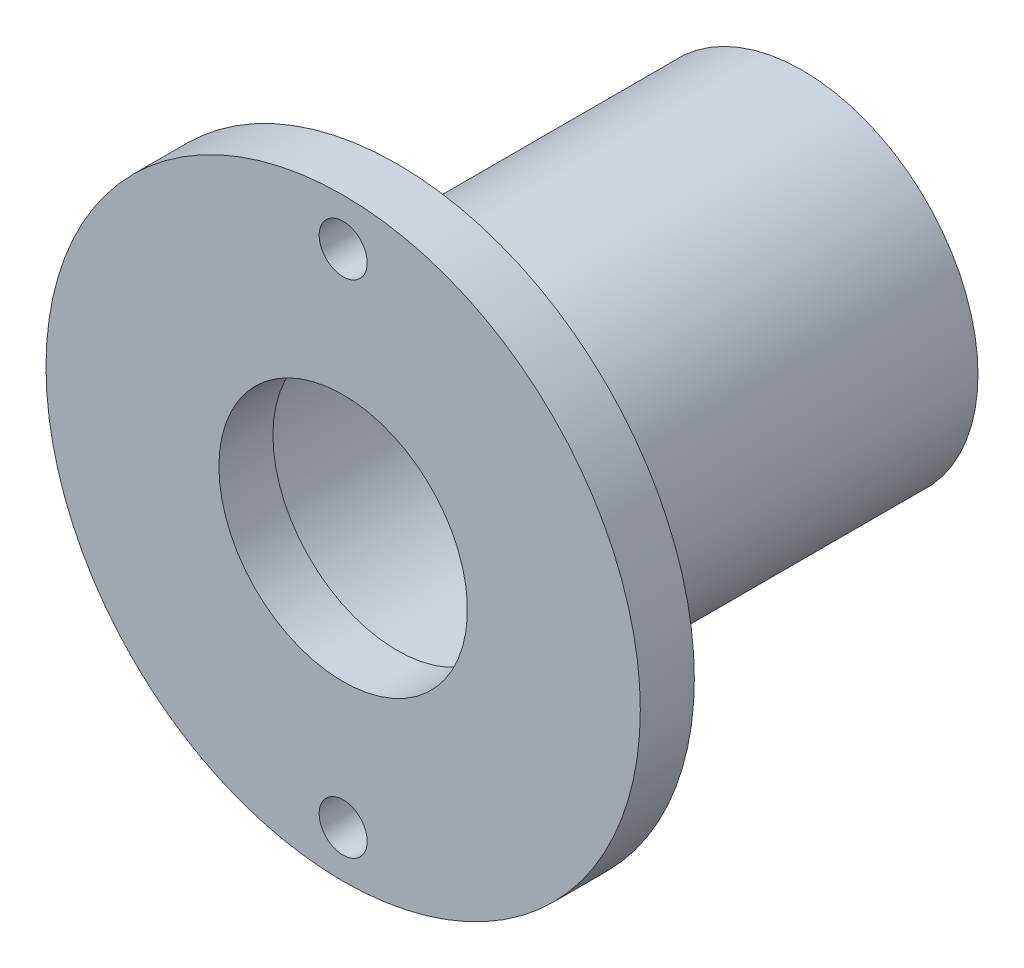
from build123d import *

# Parameters (mm, degrees)
F_0_CLEARANCE_HOLE1_D     = 1.778
F_0_CLEARANCE_HOLE1_DEPTH = 19.05
F_0_CLEARANCE_HOLE1_TIP   = 0.53416509


with BuildPart() as part:
    # Sketch1 → Revolve1 (revolve)
    with BuildSketch(Plane(origin=(0, 0, 0), x_dir=(0, 0, -1), z_dir=(1, 0, 0)), mode=Mode.PRIVATE) as revolve1_sk:
        Polygon((0, 11), (0, 4.6), (2, 4.6), (2, 5.275), (8, 5.275), (8, 5.5), (17, 5.5), (17, 6.5), (2, 6.5), (2, 11), align=None)
    revolve(revolve1_sk.sketch.rotate(Axis((0, 0, 0), (0, 0, 1)), 90), axis=Axis((0, 0, 0), (0, 0, 1)))  # turned: the seam where the file's is

    # #0 Clearance Hole1
    with Locations(Plane(origin=(0, 0, -2), x_dir=(-1, 0, 0), z_dir=(0, 0, -1))):
        with Locations((0, 9.2718), (0, -9.2718)):
            Hole(F_0_CLEARANCE_HOLE1_D / 2, depth=F_0_CLEARANCE_HOLE1_DEPTH)
            with Locations((0, 0, -(F_0_CLEARANCE_HOLE1_DEPTH + F_0_CLEARANCE_HOLE1_TIP / 2))):  # 118° drill point
                Cone(0, F_0_CLEARANCE_HOLE1_D / 2, F_0_CLEARANCE_HOLE1_TIP, mode=Mode.SUBTRACT)


solid = part.part
